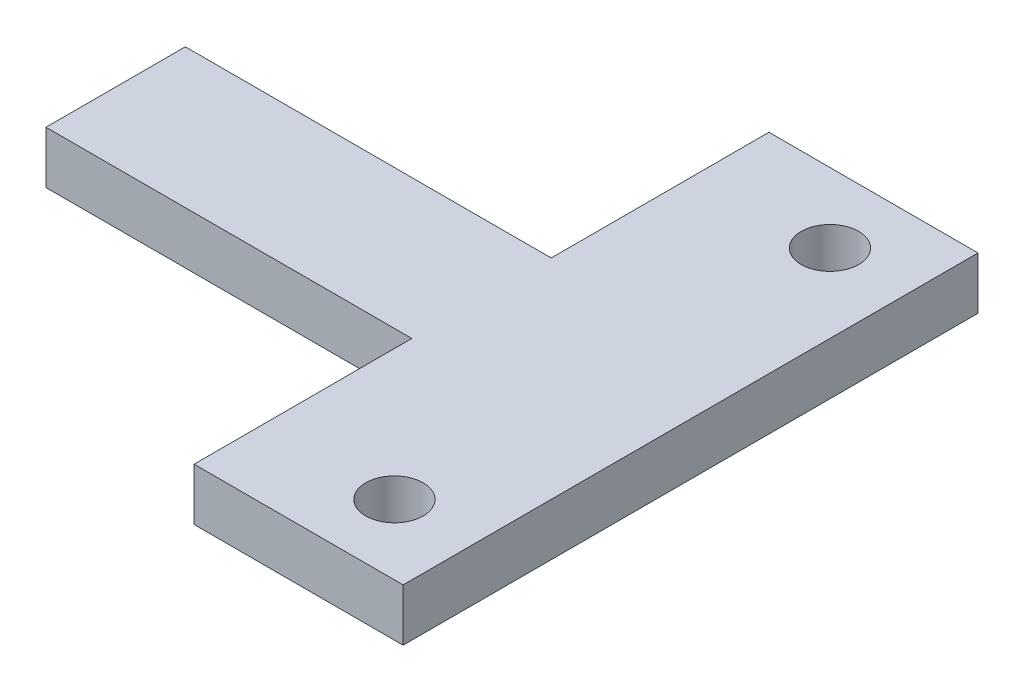
from build123d import *

# Parameters (mm, degrees)
SKETCH1_R           = 1.65
BOSS_EXTRUDE1_DEPTH = 3


with BuildPart() as part:
    # Sketch1 → Boss-Extrude1 (new body)
    with BuildSketch(Plane(origin=(0, 0, 0), x_dir=(1, 0, 0), z_dir=(0, 1, 0))):
        Polygon((-10.5, 4), (-10.5, -4), (10.5, -4), (10.5, -16.5), (22.5, -16.5), (22.5, 16.5), (10.5, 16.5), (10.5, 4), align=None)
        with Locations((18, 12.5)):
            Circle(SKETCH1_R, mode=Mode.SUBTRACT)
        with Locations((18, -12.5)):
            Circle(SKETCH1_R, mode=Mode.SUBTRACT)
    extrude(amount=BOSS_EXTRUDE1_DEPTH)


solid = part.part
